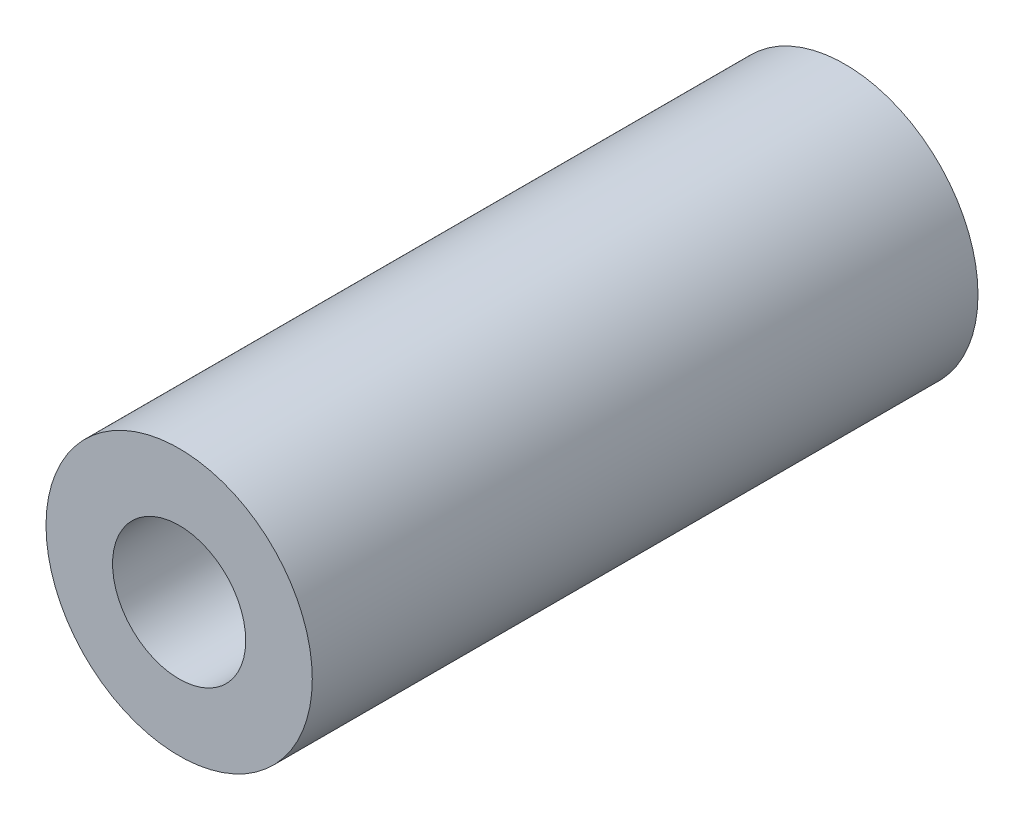
from build123d import *

# Parameters (mm, degrees)
SKETCH_1_R      = 4
SKETCH_1_R_2    = 2
EXTRUDE_1_DEPTH = 10


with BuildPart() as part:
    # 草图1 → 凸台-拉伸1 (new body, symmetric)
    with BuildSketch(Plane.XY):
        Circle(SKETCH_1_R)
        Circle(SKETCH_1_R_2, mode=Mode.SUBTRACT)
    extrude(amount=EXTRUDE_1_DEPTH, both=True)


solid = part.part
